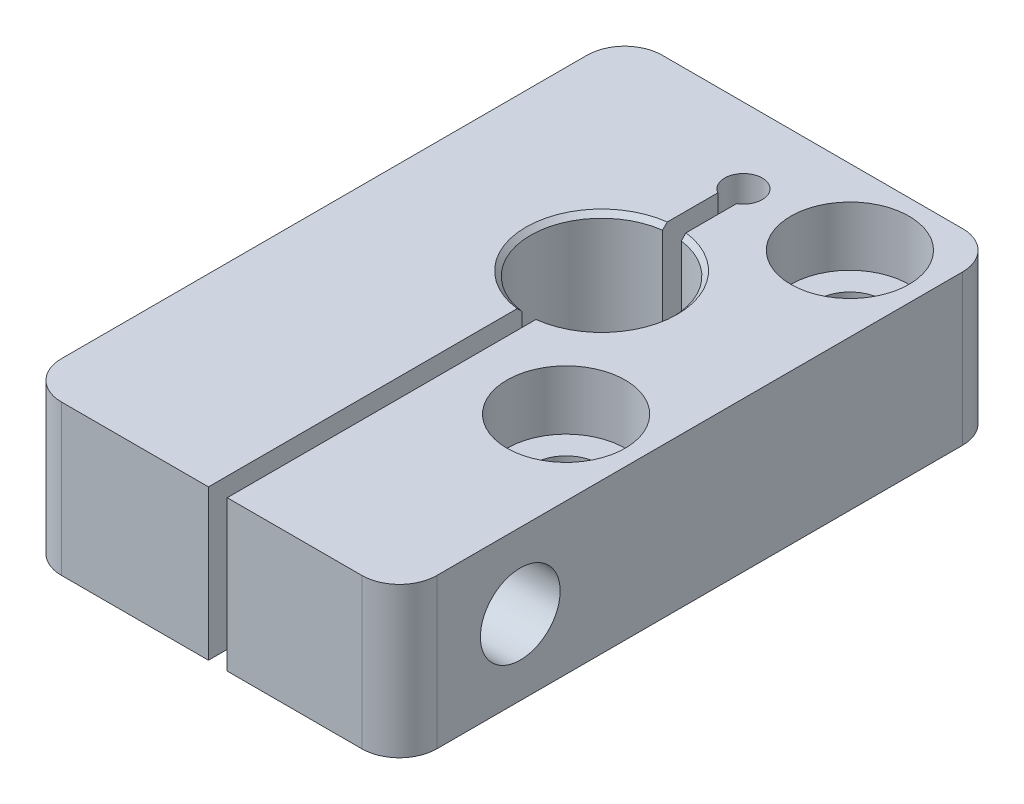
from build123d import *

# Parameters (mm, degrees)
SKETCH1_W                            = 12.7
SKETCH1_H                            = 31.75
EXTRUDE1_DEPTH                       = 25.4
CBORE_FOR_M5_SHCS1_D                 = 5.5
CBORE_FOR_M5_SHCS1_DEPTH             = 12.7
CBORE_FOR_M5_SHCS1_CBORE_D           = 10
CBORE_FOR_M5_SHCS1_CBORE_DEPTH       = 5
CUT_EXTRUDE1_REACH                   = 14.7
F_17_64_0_26563_DIAMETER_HOLE1_D     = 6.747002
F_17_64_0_26563_DIAMETER_HOLE1_DEPTH = 14.55625
M6X1_0_TAPPED_HOLE1_D                = 5
M6X1_0_TAPPED_HOLE1_DEPTH            = 15.60625
FILLET1_R                            = 3.175
CHAMFER1_SIZE                        = 0.396875


with BuildPart() as part:
    # Sketch1 → Extrude1 (new body, symmetric)
    with BuildSketch(Plane(origin=(0, 0, 0), x_dir=(0, 1, 0), z_dir=(0, 0, 1))):
        Rectangle(SKETCH1_W, SKETCH1_H)
    extrude(amount=EXTRUDE1_DEPTH, both=True)

    # CBORE for M5 SHCS1
    with Locations(Plane(origin=(0, 6.35, 0), x_dir=(-1, 0, 0), z_dir=(0, 1, 0))):
        with Locations((-9.525, -19.05), (-9.525, 4.95)):
            CounterBoreHole(CBORE_FOR_M5_SHCS1_D / 2, CBORE_FOR_M5_SHCS1_CBORE_D / 2, CBORE_FOR_M5_SHCS1_CBORE_DEPTH, depth=CBORE_FOR_M5_SHCS1_DEPTH)

    # Sketch4 → Cut-Extrude1 (cut, up to next)
    with BuildSketch(Plane(origin=(0, 6.35, 0), x_dir=(1, 0, 0), z_dir=(0, 1, 0)), mode=Mode.PRIVATE) as cut_extrude1_sk1:
        with BuildLine():
            Line((-0.26875, 17.675184671), (-0.26875, 12.997264996))
            ThreePointArc((-0.26875, 12.997264996), (-5.475, 7.05), (-0.26875, 1.102735004))
            Line((-0.26875, 1.102735004), (-0.26875, -25.4))
            Line((-0.26875, -25.4), (1.31875, -25.4))
            Line((1.31875, -25.4), (1.31875, 1.102735004))
            ThreePointArc((1.31875, 1.102735004), (6.525, 7.05), (1.31875, 12.997264996))
            Line((1.31875, 12.997264996), (1.31875, 17.675184671))
            ThreePointArc((1.31875, 17.675184671), (0.525, 20.6375), (-0.26875, 17.675184671))
        make_face()
    cut_extrude1_tool1 = extrude(cut_extrude1_sk1.sketch, amount=-CUT_EXTRUDE1_REACH, mode=Mode.PRIVATE) & part.part
    add(cut_extrude1_tool1.solids().sort_by_distance((0.525, 6.35, -3.20917))[0], mode=Mode.SUBTRACT)

    # 17/64 (0.26563) Diameter Hole1
    with Locations(Plane(origin=(15.875, 0, 0), x_dir=(0, 0, -1), z_dir=(1, 0, 0))):
        with Locations((-15.175, 0)):
            Hole(F_17_64_0_26563_DIAMETER_HOLE1_D / 2, depth=F_17_64_0_26563_DIAMETER_HOLE1_DEPTH)

    # M6x1.0 Tapped Hole1
    with Locations(Plane(origin=(-0.26875, 0, 0), x_dir=(0, 0, -1), z_dir=(1, 0, 0))):
        with Locations((-15.175, 0)):
            Hole(M6X1_0_TAPPED_HOLE1_D / 2, depth=M6X1_0_TAPPED_HOLE1_DEPTH)

    # Fillet1
    fillet1_edges = [part.edges().sort_by_distance(p)[0] for p in [
        (15.875, 0, 25.4),
        (15.875, 0, -25.4),
        (-15.875, 0, -25.4),
        (-15.875, 0, 25.4),
    ]]
    fillet(fillet1_edges, radius=FILLET1_R)

    # Chamfer1
    chamfer1_edges = [part.edges().sort_by_distance(p)[0] for p in [
        (-5.475, 6.35, -7.05),
        (6.525, 6.35, -7.05),
        (6.525, -6.35, -7.05),
        (-5.475, -6.35, -7.05),
    ]]
    chamfer(chamfer1_edges, length=CHAMFER1_SIZE)


solid = part.part
